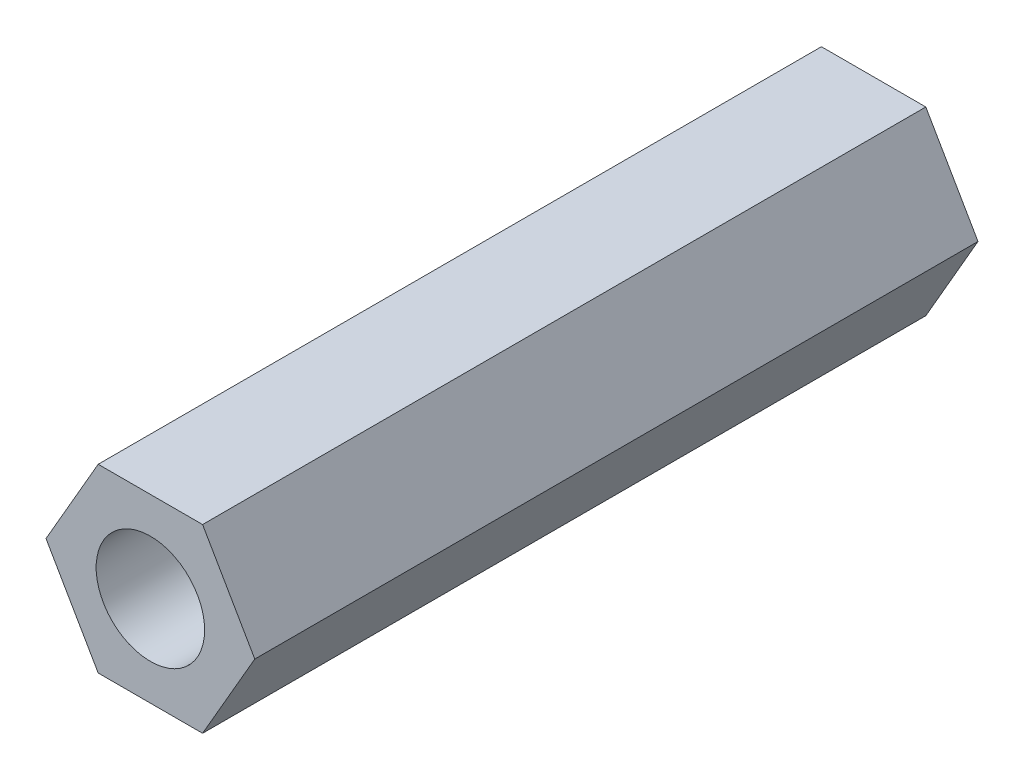
from build123d import *

# Parameters (mm, degrees)
SKETCH_1_R      = 1.5
EXTRUDE_1_DEPTH = 20


with BuildPart() as part:
    # 草图1 → 凸台-拉伸1 (new body)
    with BuildSketch(Plane.XY):
        Polygon((1.443375673, -2.5), (2.886751346, 0), (1.443375673, 2.5), (-1.443375673, 2.5), (-2.886751346, 0), (-1.443375673, -2.5), align=None)
        Circle(SKETCH_1_R, mode=Mode.SUBTRACT)
    extrude(amount=EXTRUDE_1_DEPTH)


solid = part.part
